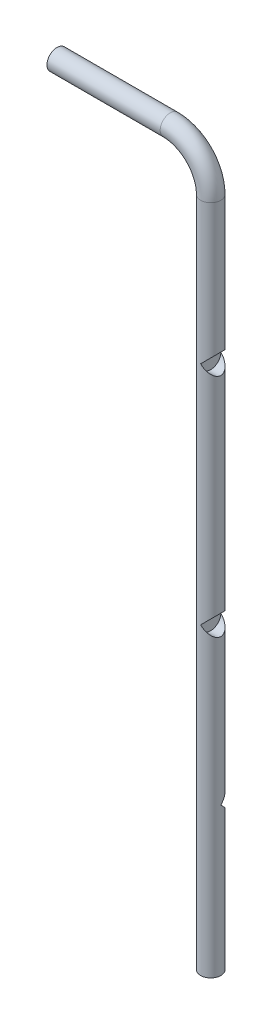
from build123d import *

# Parameters (mm, degrees)
SWEEP1_PROFILE_R   = 12.5
SKETCH8_R          = 12.5
CUT_EXTRUDE3_DEPTH = 21
SKETCH2_R          = 12.5
CUT_EXTRUDE5_DEPTH = 13


with BuildPart() as part:
    # Sweep1: sweep along a path in Sketch1
    with BuildLine(Plane.XY) as sweep1_path:
        Line((0, 0), (0, 830))
        ThreePointArc((0, 830), (-14.644660941, 865.355339059), (-50, 880))
        Line((-50, 880), (-190, 880))
    # Sweep1 profile (on start of the path) → Sweep1 (sweep)
    with BuildSketch(Plane.ZX):
        Circle(SWEEP1_PROFILE_R)
    sweep(path=sweep1_path.line)

    # Sketch8 → Cut-Extrude3 (cut)
    with BuildSketch(Plane(origin=(0, 0, 0), x_dir=(0, 0, -1), z_dir=(1, 0, 0))):
        with Locations((0, 655.01)):
            Circle(SKETCH8_R)
        with Locations((0, 375.5)):
            Circle(SKETCH8_R)
    extrude(amount=CUT_EXTRUDE3_DEPTH, mode=Mode.SUBTRACT)

    # Sketch2 → Cut-Extrude5 (cut)
    with BuildSketch(Plane.XY):
        with Locations((0, 182.5)):
            Circle(SKETCH2_R)
    extrude(amount=-CUT_EXTRUDE5_DEPTH, mode=Mode.SUBTRACT)


solid = part.part
